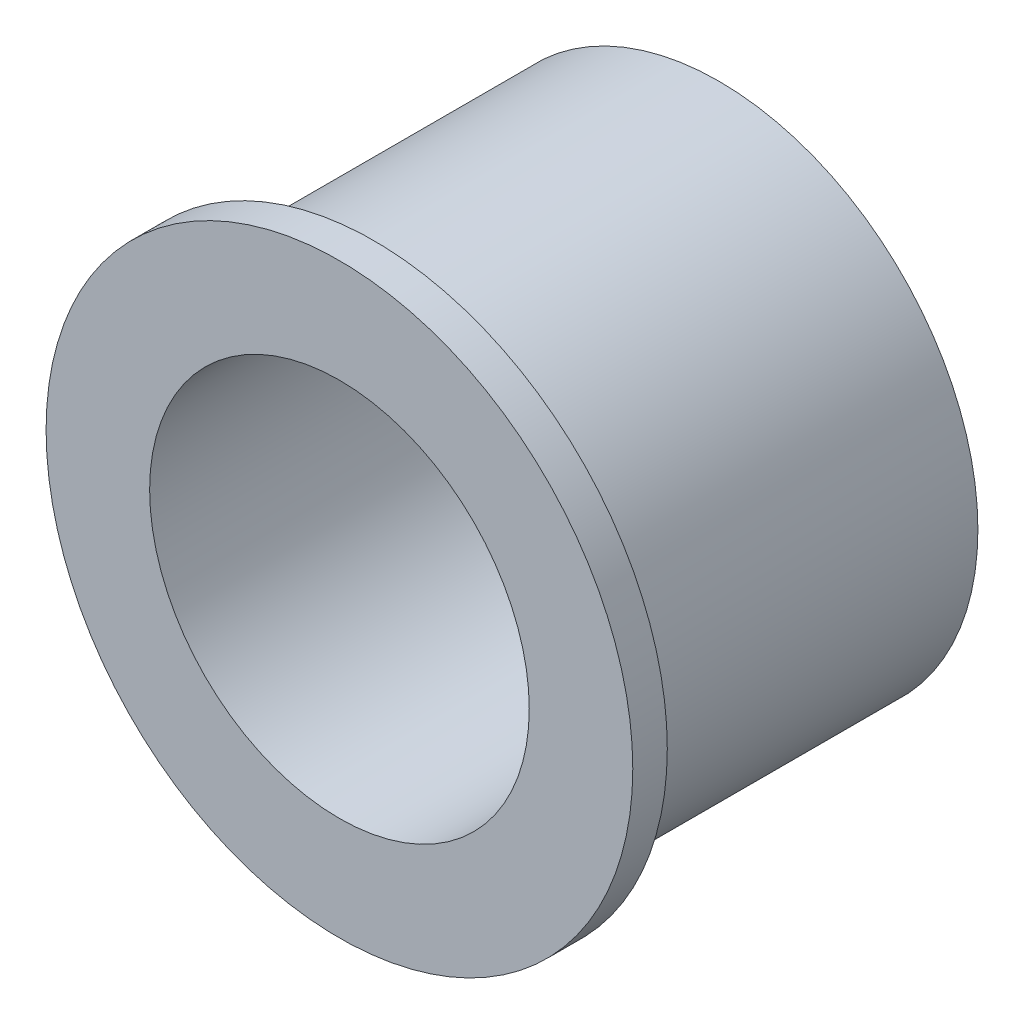
from build123d import *

# Parameters (mm, degrees)
SKETCH1_R           = 37.5
SKETCH1_R_2         = 27.5
BOSS_EXTRUDE1_DEPTH = 50
SKETCH2_R           = 42.5
SKETCH2_R_2         = 27.5
BOSS_EXTRUDE2_DEPTH = 5
SKETCH3_R           = 2
CUT_EXTRUDE1_DEPTH  = 10


with BuildPart() as part:
    # Sketch1 → Boss-Extrude1 (new body)
    with BuildSketch(Plane.XY):
        Circle(SKETCH1_R)
        Circle(SKETCH1_R_2, mode=Mode.SUBTRACT)
    extrude(amount=BOSS_EXTRUDE1_DEPTH)

    # Sketch2 → Boss-Extrude2 (add)
    with BuildSketch(Plane.XY.offset(50)):
        Circle(SKETCH2_R)
        Circle(SKETCH2_R_2, mode=Mode.SUBTRACT)
    extrude(amount=BOSS_EXTRUDE2_DEPTH)

    # Sketch3 → Cut-Extrude1 (cut)
    with BuildSketch(Plane(origin=(0, 0, 0), x_dir=(-1, 0, 0), z_dir=(0, 0, -1))):
        with Locations((0, 32.5)):
            Circle(SKETCH3_R)
        with Locations((22.980970389, 22.980970389)):
            Circle(SKETCH3_R)
        with Locations((32.5, 0)):
            Circle(SKETCH3_R)
        with Locations((22.980970389, -22.980970389)):
            Circle(SKETCH3_R)
        with Locations((0, -32.5)):
            Circle(SKETCH3_R)
        with Locations((-22.980970389, -22.980970389)):
            Circle(SKETCH3_R)
        with Locations((-32.5, 0)):
            Circle(SKETCH3_R)
        with Locations((-22.980970389, 22.980970389)):
            Circle(SKETCH3_R)
    extrude(amount=-CUT_EXTRUDE1_DEPTH, mode=Mode.SUBTRACT)


solid = part.part
